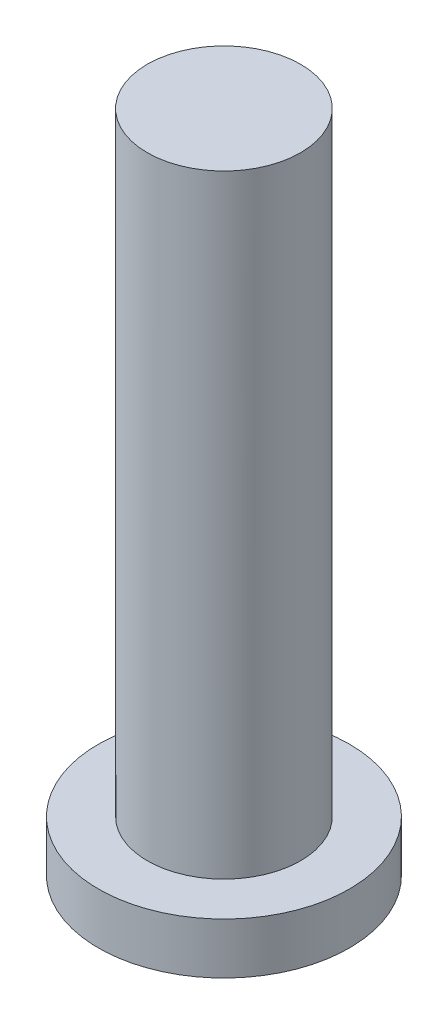
from build123d import *

# Parameters (mm, degrees)
ESBO_O1_R                = 1.5
RESSALTO_EXTRUS_O1_DEPTH = 12
ESBO_O2_R                = 2.456057754
RESSALTO_EXTRUS_O2_DEPTH = 1


with BuildPart() as part:
    # Esboço1 → Ressalto-extrusão1 (new body)
    with BuildSketch(Plane(origin=(0, 0, 0), x_dir=(1, 0, 0), z_dir=(0, 1, 0))):
        Circle(ESBO_O1_R)
    extrude(amount=RESSALTO_EXTRUS_O1_DEPTH)

    # Esboço2 → Ressalto-extrusão2 (add)
    with BuildSketch(Plane(origin=(0, 0, 0), x_dir=(-1, 0, 0), z_dir=(0, -1, 0))):
        Circle(ESBO_O2_R)
    extrude(amount=RESSALTO_EXTRUS_O2_DEPTH)


solid = part.part
